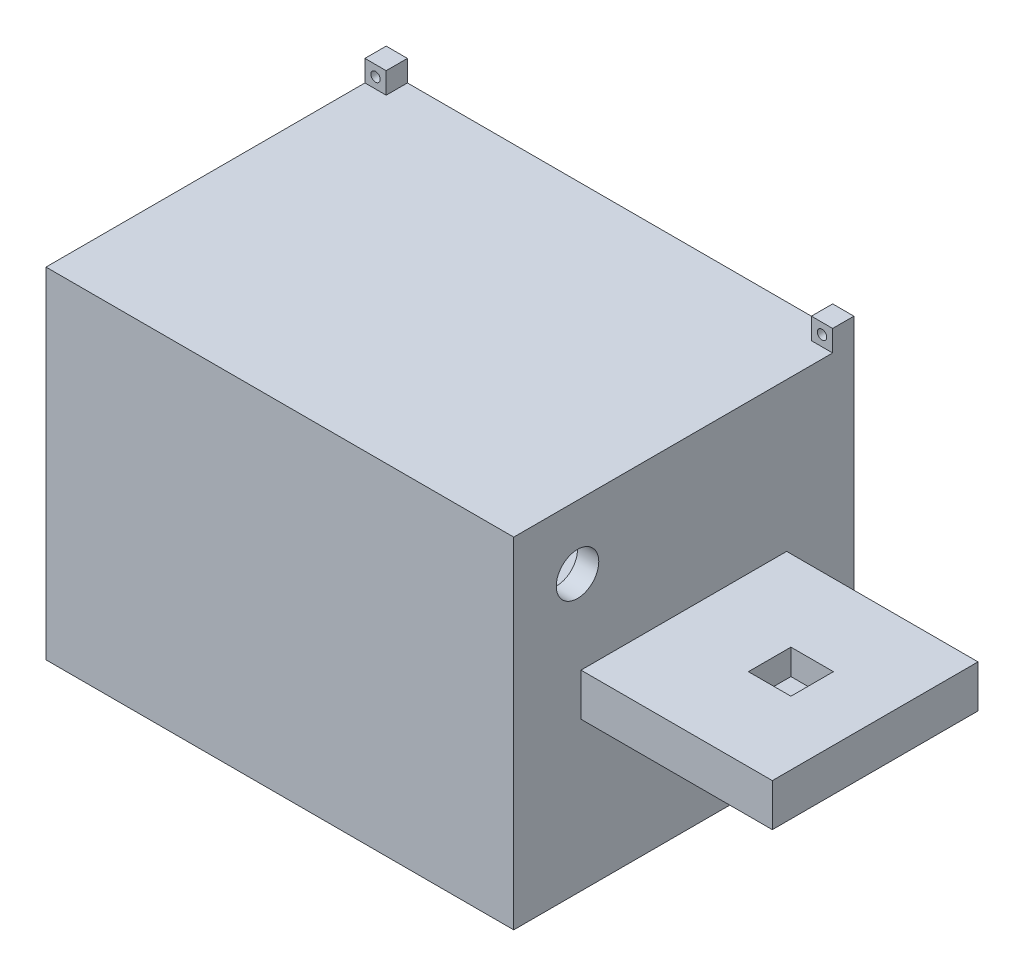
from build123d import *

# Parameters (mm, degrees)
SKETCH_1_W           = 155
SKETCH_1_H           = 80
EXTRUDE_1_DEPTH      = 80
SKETCH_6_W           = 45
SKETCH_6_H           = 80
CUT_EXTRUDE_1_DEPTH  = 35
SKETCH_5_W           = 45
SKETCH_5_H           = 80
CUT_EXTRUDE_2_DEPTH  = 35
SKETCH_7_W           = 100
SKETCH_7_H           = 70
CUT_EXTRUDE_3_DEPTH  = 75
SKETCH_8_W           = 107.8
SKETCH_8_H           = 77.8
SKETCH_8_W_2         = 102.2
SKETCH_8_H_2         = 72.2
CUT_EXTRUDE_4_DEPTH  = 10
SKETCH_9_R           = 5
CUT_EXTRUDE_5_DEPTH  = 10
SKETCH_10_W          = 21.5
SKETCH_10_H          = 15
CUT_EXTRUDE_6_DEPTH  = 10
SKETCH_12_W          = 15.816906699
SKETCH_12_H          = 10
CUT_EXTRUDE_7_DEPTH  = 45
CUT_EXTRUDE_8_DEPTH  = 3
SKETCH_15_W          = 10
SKETCH_15_H          = 10
CUT_EXTRUDE_9_DEPTH  = 6
SKETCH_17_R          = 1.095275866
CUT_EXTRUDE_11_DEPTH = 7
SKETCH_18_W          = 5
SKETCH_18_H          = 5
SKETCH_18_R          = 1.1
EXTRUDE_2_DEPTH      = 5


with BuildPart() as part:
    # 草圖1 → 填料-伸長1 (new body)
    with BuildSketch(Plane.XY):
        with Locations((1.991097826, 5.58988764)):
            Rectangle(SKETCH_1_W, SKETCH_1_H)
    extrude(amount=EXTRUDE_1_DEPTH)

    # 草圖6 → 除料-伸長1 (cut)
    with BuildSketch(Plane(origin=(0, 45.58988764, 0), x_dir=(1, 0, 0), z_dir=(0, 1, 0))):
        with Locations((56.991097826, -40)):
            Rectangle(SKETCH_6_W, SKETCH_6_H)
    extrude(amount=-CUT_EXTRUDE_1_DEPTH, mode=Mode.SUBTRACT)

    # 草圖5 → 除料-伸長2 (cut)
    with BuildSketch(Plane.XZ.offset(34.41011236)):
        with Locations((56.991097826, 40)):
            Rectangle(SKETCH_5_W, SKETCH_5_H)
    extrude(amount=-CUT_EXTRUDE_2_DEPTH, mode=Mode.SUBTRACT)

    # 草圖7 → 除料-伸長3 (cut)
    with BuildSketch(Plane.XY):
        with Locations((-20.508902174, 5.58988764)):
            Rectangle(SKETCH_7_W, SKETCH_7_H)
    extrude(amount=CUT_EXTRUDE_3_DEPTH, mode=Mode.SUBTRACT)

    # 草圖8 → 除料-伸長4 (cut)
    with BuildSketch(Plane(origin=(0, 0, 0), x_dir=(-1, 0, 0), z_dir=(0, 0, -1))):
        with Locations((20.508902174, 5.58988764)):
            Rectangle(SKETCH_8_W, SKETCH_8_H)
        with Locations((20.508902174, 5.58988764)):
            Rectangle(SKETCH_8_W_2, SKETCH_8_H_2, mode=Mode.SUBTRACT)
    extrude(amount=-CUT_EXTRUDE_4_DEPTH, mode=Mode.SUBTRACT)

    # 草圖9 → 除料-伸長5 (cut)
    with BuildSketch(Plane(origin=(34.491097826, 0, 0), x_dir=(0, 0, -1), z_dir=(1, 0, 0))):
        with Locations((-65, 30.58988764)):
            Circle(SKETCH_9_R)
        with Locations((-20, -19.41011236)):
            Circle(SKETCH_9_R)
    extrude(amount=-CUT_EXTRUDE_5_DEPTH, mode=Mode.SUBTRACT)

    # 草圖10 → 除料-伸長6 (cut)
    with BuildSketch(Plane(origin=(0, -34.41011236, 0), x_dir=(-1, 0, 0), z_dir=(0, -1, 0))):
        with Locations((24.758902174, -22.5)):
            Rectangle(SKETCH_10_W, SKETCH_10_H)
    extrude(amount=-CUT_EXTRUDE_6_DEPTH, mode=Mode.SUBTRACT)

    # 草圖12 → 除料-伸長7 (cut)
    with BuildSketch(Plane(origin=(34.491097826, 0, 0), x_dir=(0, 0, -1), z_dir=(1, 0, 0))):
        with Locations((-72.09154665, 5.58988764)):
            Rectangle(SKETCH_12_W, SKETCH_12_H)
        with Locations((-7.90845335, 5.58988764)):
            Rectangle(SKETCH_12_W, SKETCH_12_H)
    extrude(amount=CUT_EXTRUDE_7_DEPTH, mode=Mode.SUBTRACT)

    # 草圖14 → 除料-伸長8 (cut)
    with BuildSketch(Plane(origin=(0, 0.58988764, 0), x_dir=(-1, 0, 0), z_dir=(0, -1, 0))):
        with BuildLine():
            Line((-58.137150435, -35.10282789), (-41.645964254, -38.5))
            ThreePointArc((-41.645964254, -38.5), (-40.145964254, -40), (-41.645964254, -41.5))
            Line((-41.645964254, -41.5), (-58.137150435, -44.89717211))
            ThreePointArc((-58.137150435, -44.89717211), (-59.145964254, -45), (-60.154778073, -44.89717211))
            Line((-60.154778073, -44.89717211), (-76.645964254, -41.5))
            ThreePointArc((-76.645964254, -41.5), (-78.145964254, -40), (-76.645964254, -38.5))
            Line((-76.645964254, -38.5), (-60.154778073, -35.10282789))
            ThreePointArc((-60.154778073, -35.10282789), (-59.145964254, -35), (-58.137150435, -35.10282789))
        make_face()
    extrude(amount=-CUT_EXTRUDE_8_DEPTH, mode=Mode.SUBTRACT)

    # 草圖15 → 除料-伸長9 (cut)
    with BuildSketch(Plane(origin=(0, 10.58988764, 0), x_dir=(1, 0, 0), z_dir=(0, 1, 0))):
        with Locations((59.491097826, -39.816906699)):
            Rectangle(SKETCH_15_W, SKETCH_15_H)
    extrude(amount=-CUT_EXTRUDE_9_DEPTH, mode=Mode.SUBTRACT)

    # 草圖17 → 除料-伸長11 (cut)
    with BuildSketch(Plane(origin=(0, 0.58988764, 0), x_dir=(-1, 0, 0), z_dir=(0, -1, 0))):
        with Locations((-59.145964254, -40)):
            Circle(SKETCH_17_R)
    extrude(amount=-CUT_EXTRUDE_11_DEPTH, mode=Mode.SUBTRACT)

    # 草圖18 → 填料-伸長2 (add)
    with BuildSketch(Plane.XY):
        with Locations((31.991097826, 48.08988764)):
            Rectangle(SKETCH_18_W, SKETCH_18_H)
        with Locations((31.991097826, 48.08988764)):
            Circle(SKETCH_18_R, mode=Mode.SUBTRACT)
        with Locations((-73.008902174, 48.08988764)):
            Rectangle(SKETCH_18_W, SKETCH_18_H)
        with Locations((-73.008902174, 48.08988764)):
            Circle(SKETCH_18_R, mode=Mode.SUBTRACT)
        with Locations((-73.008902174, -36.91011236)):
            Rectangle(SKETCH_18_W, SKETCH_18_H)
        with Locations((-73.008902174, -36.91011236)):
            Circle(SKETCH_18_R, mode=Mode.SUBTRACT)
        with Locations((31.991097826, -36.91011236)):
            Rectangle(SKETCH_18_W, SKETCH_18_H)
        with Locations((31.991097826, -36.91011236)):
            Circle(SKETCH_18_R, mode=Mode.SUBTRACT)
    extrude(amount=EXTRUDE_2_DEPTH)


solid = part.part
